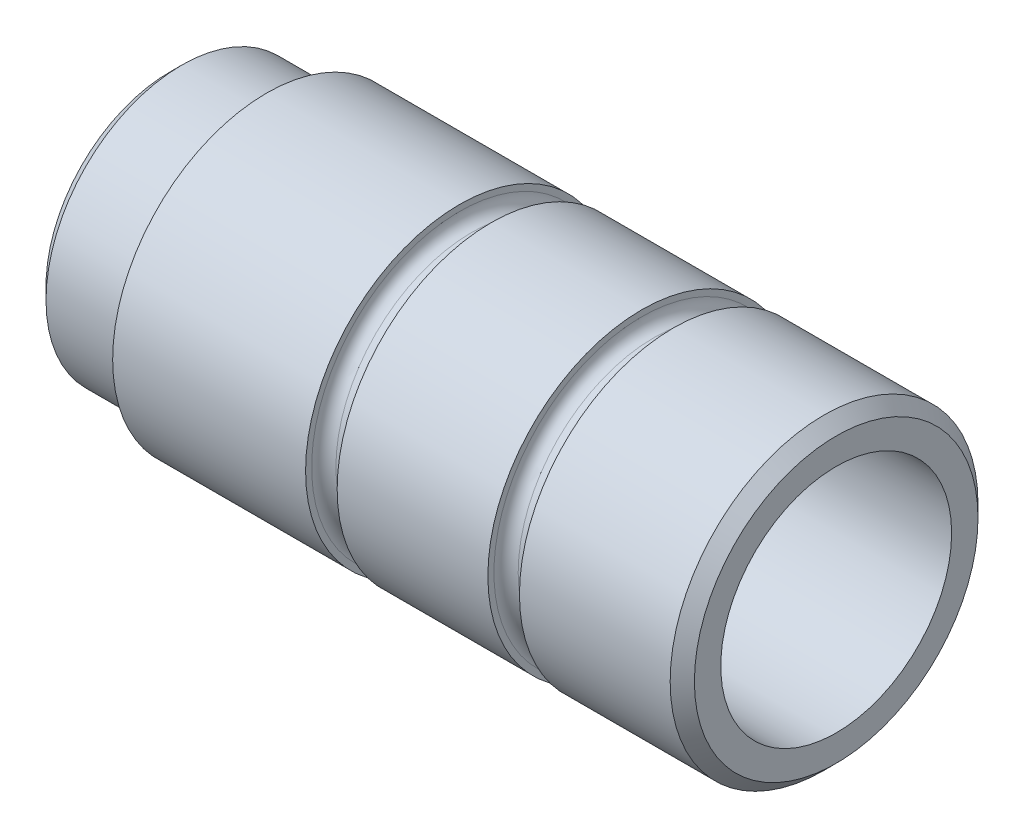
from build123d import *


with BuildPart() as part:
    # Sketch1 → Revolve1 (revolve)
    with BuildSketch(Plane.XY):
        with BuildLine():
            Line((0, 9.525), (-55, 9.525))
            Line((-55, 9.525), (-55, 10.2))
            Line((-55, 10.2), (-54, 11.2))
            Line((-54, 11.2), (-48, 11.2))
            ThreePointArc((-48, 11.2), (-47.292893219, 11.492893219), (-47, 12.2))
            Line((-47, 12.2), (-47, 12.7))
            Line((-47, 12.7), (-31.08207122, 12.7))
            Line((-31.08207122, 12.7), (-31.08207122, 12.2))
            ThreePointArc((-31.08207122, 12.2), (-30.789178001, 11.492893219), (-30.08207122, 11.2))
            Line((-30.08207122, 11.2), (-29.477097815, 11.2))
            ThreePointArc((-29.477097815, 11.2), (-28.769991033, 11.492893219), (-28.477097815, 12.2))
            Line((-28.477097815, 12.2), (-28.477097815, 12.7))
            Line((-28.477097815, 12.7), (-16.04103561, 12.7))
            Line((-16.04103561, 12.7), (-16.04103561, 12.2))
            ThreePointArc((-16.04103561, 12.2), (-15.748142391, 11.492893219), (-15.04103561, 11.2))
            Line((-15.04103561, 11.2), (-14.436062205, 11.2))
            ThreePointArc((-14.436062205, 11.2), (-13.728955423, 11.492893219), (-13.436062205, 12.2))
            Line((-13.436062205, 12.2), (-13.436062205, 12.7))
            Line((-13.436062205, 12.7), (-1, 12.7))
            Line((-1, 12.7), (0, 11.7))
            Line((0, 11.7), (0, 9.525))
        make_face()
    revolve(axis=Axis((19.168296655, 0, 0), (-1, 0, 0)))


solid = part.part
